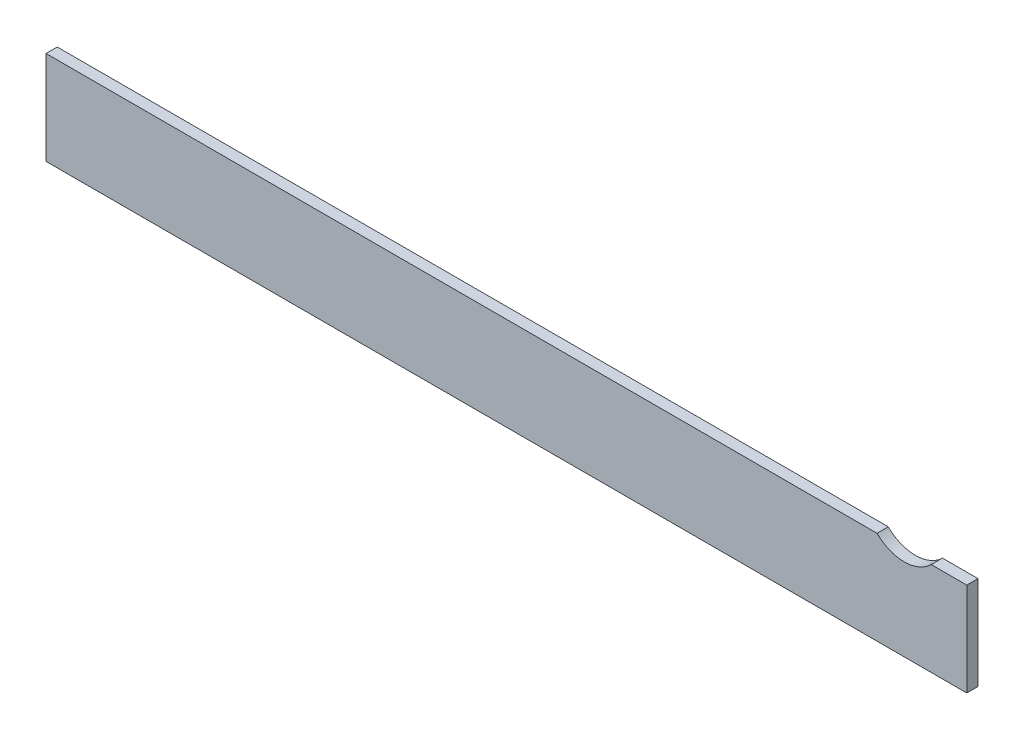
from build123d import *

# Parameters (mm, degrees)
SALIENTE_EXTRUIR1_DEPTH = 12


with BuildPart() as part:
    # Croquis1 → Saliente-Extruir1 (new body)
    with BuildSketch(Plane.XY):
        with BuildLine():
            Line((0, 0), (985, 0))
            Line((985, 0), (985, 100))
            Line((985, 100), (946.952353927, 100))
            ThreePointArc((946.952353927, 100), (918, 88.021483703), (889.047646073, 100))
            Line((889.047646073, 100), (0, 100))
            Line((0, 100), (0, 0))
        make_face()
    extrude(amount=SALIENTE_EXTRUIR1_DEPTH)


solid = part.part
